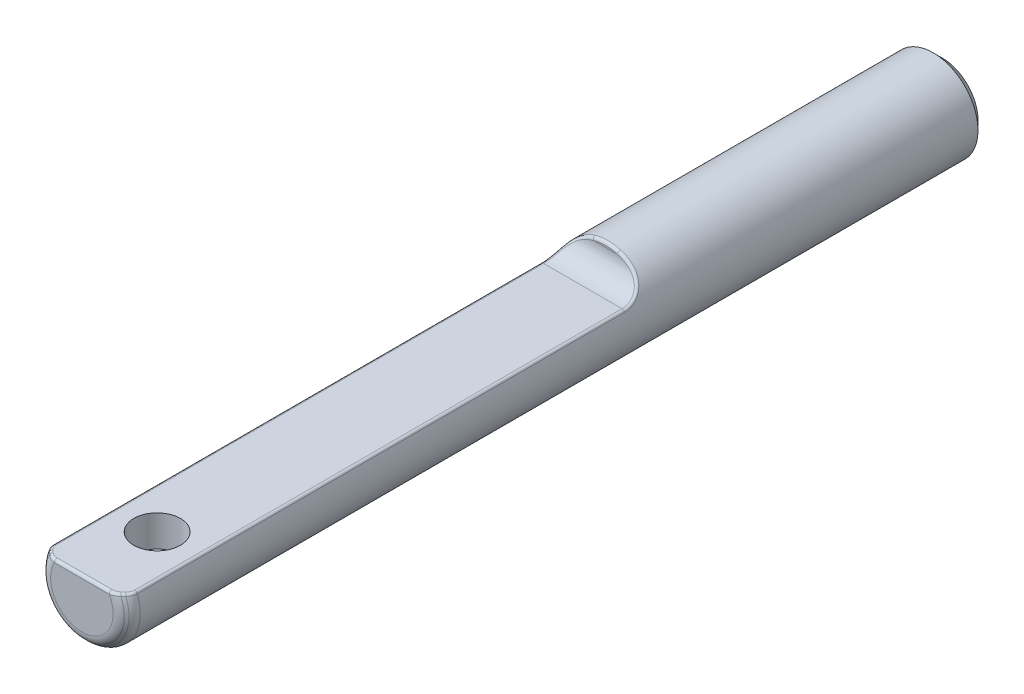
from build123d import *

# Parameters (mm, degrees)
SKETCH1_R          = 3.175
EXTRUDE1_DEPTH     = 30.48
CHAMFER1_SIZE      = 0.635
EXTRUDE7_DEPTH     = 38.084
FILLET1_R          = 1.5875
FILLET3_R          = 0.79375
FILLET4_R          = 0.1984375
SKETCH14_R         = 1.651
CUT_EXTRUDE1_DEPTH = 2.2225


with BuildPart() as part:
    # Sketch1 → Extrude1 (new body, symmetric)
    with BuildSketch(Plane.XY):
        Circle(SKETCH1_R)
    extrude(amount=EXTRUDE1_DEPTH, both=True)

    # Chamfer1
    chamfer1_edges = [part.edges().sort_by_distance(p)[0] for p in [
        (-3.175, 0, -30.48),
        (-3.175, 0, 30.48),
    ]]
    chamfer(chamfer1_edges, length=CHAMFER1_SIZE)

    # Sketch13 → Extrude7 (cut, through all)
    with BuildSketch(Plane.XY.offset(-6.604)):
        with BuildLine():
            Line((-2.909935566, 1.27), (2.909935566, 1.27))
            ThreePointArc((2.909935566, 1.27), (0, 3.175), (-2.909935566, 1.27))
        make_face()
    extrude(amount=EXTRUDE7_DEPTH, mode=Mode.SUBTRACT)

    # Fillet1
    fillet1_edges = [part.edges().sort_by_distance(p)[0] for p in [
        (0, 1.27, -6.604),
    ]]
    fillet(fillet1_edges, radius=FILLET1_R)

    # Fillet3
    fillet3_edges = [part.edges().sort_by_distance(p)[0] for p in [
        (0, -2.54, 30.48),
        (-0.648683119, -3.108027544, 29.845),
    ]]
    fillet(fillet3_edges, radius=FILLET3_R)

    # Fillet4
    fillet4_edges = [part.edges().sort_by_distance(p)[0] for p in [
        (0, 3.175, -6.604),
        (2.5327835, 1.914584225, -6.29363198),
        (-2.5327835, 1.914584225, -6.29363198),
        (0, 1.27, 30.48),
        (2.909935566, 1.27, 12.249858992),
        (-2.909935566, 1.27, 12.249858992),
        (-2.559573738, 1.27, 30.162672977),
        (2.559573738, 1.27, 30.162672977),
        (2.842060138, 1.27, 29.823974262),
        (-2.842060075, 1.27, 29.823974247),
        (-2.158993926, 1.27, 30.423700487),
        (2.158993926, 1.27, 30.423700487),
    ]]
    fillet(fillet4_edges, radius=FILLET4_R)

    # Sketch14 → Cut-Extrude1 (cut)
    with BuildSketch(Plane(origin=(0, 1.27, 0), x_dir=(1, 0, 0), z_dir=(0, 1, 0))):
        with Locations((0.001765627, -25.146)):
            Circle(SKETCH14_R)
    extrude(amount=-CUT_EXTRUDE1_DEPTH, mode=Mode.SUBTRACT)


solid = part.part
